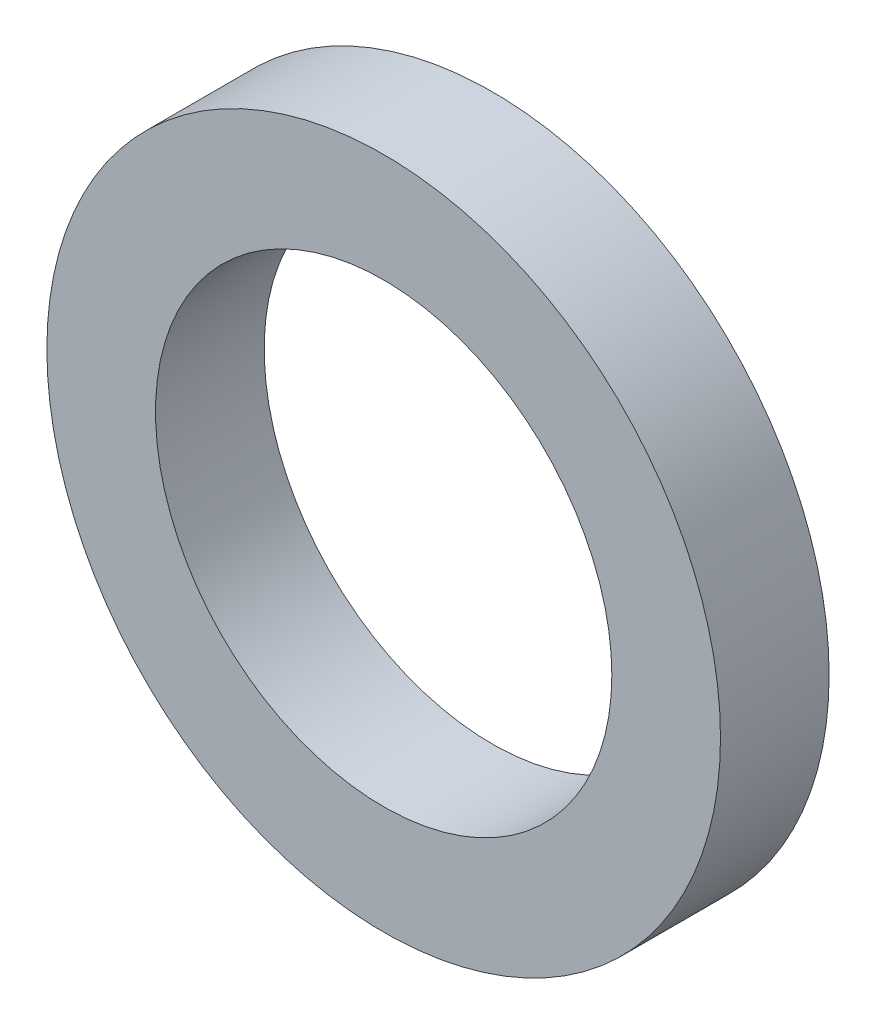
from build123d import *

# Parameters (mm, degrees)
SKETCH1_R           = 3.1
SKETCH1_R_2         = 2.1
BOSS_EXTRUDE1_DEPTH = 1


with BuildPart() as part:
    # Sketch1 → Boss-Extrude1 (new body)
    with BuildSketch(Plane.XY):
        Circle(SKETCH1_R)
        Circle(SKETCH1_R_2, mode=Mode.SUBTRACT)
    extrude(amount=BOSS_EXTRUDE1_DEPTH)


solid = part.part
